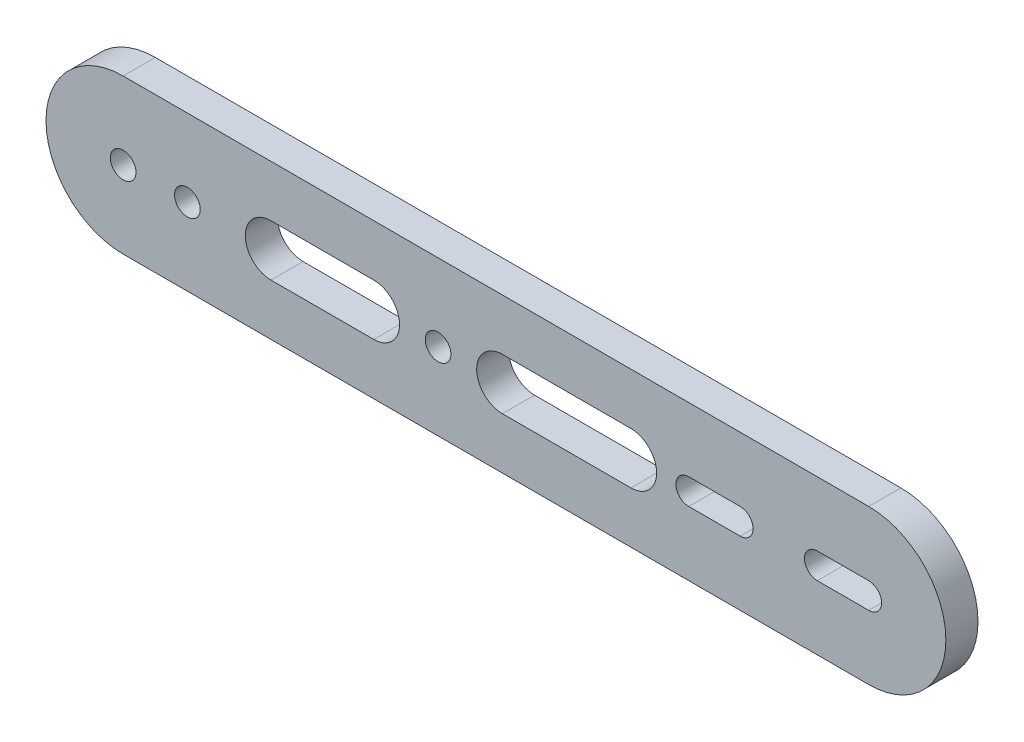
from build123d import *

# Parameters (mm, degrees)
SKETCH_1_R      = 2
EXTRUDE_1_DEPTH = 5


with BuildPart() as part:
    # 草图1 → 凸台-拉伸1 (new body)
    with BuildSketch(Plane.XY):
        with BuildLine():
            Line((0, 12), (116, 12))
            ThreePointArc((116, 12), (128, 0), (116, -12))
            Line((116, -12), (0, -12))
            ThreePointArc((0, -12), (-12, 0), (0, 12))
        make_face()
        with Locations((49, 0)):
            Circle(SKETCH_1_R, mode=Mode.SUBTRACT)
        Circle(SKETCH_1_R, mode=Mode.SUBTRACT)
        with Locations((10, 0)):
            Circle(SKETCH_1_R, mode=Mode.SUBTRACT)
        with BuildLine():
            Line((23, 4), (39, 4))
            ThreePointArc((39, 4), (43, 0), (39, -4))
            Line((39, -4), (23, -4))
            ThreePointArc((23, -4), (19, 0), (23, 4))
        make_face(mode=Mode.SUBTRACT)
        with BuildLine():
            Line((59, 4), (79, 4))
            ThreePointArc((79, 4), (83, 0), (79, -4))
            Line((79, -4), (59, -4))
            ThreePointArc((59, -4), (55, 0), (59, 4))
        make_face(mode=Mode.SUBTRACT)
        with BuildLine():
            Line((108, 2), (116, 2))
            ThreePointArc((116, 2), (118, 0), (116, -2))
            Line((116, -2), (108, -2))
            ThreePointArc((108, -2), (106, 0), (108, 2))
        make_face(mode=Mode.SUBTRACT)
        with BuildLine():
            Line((88, 2), (96, 2))
            ThreePointArc((96, 2), (98, 0), (96, -2))
            Line((96, -2), (88, -2))
            ThreePointArc((88, -2), (86, 0), (88, 2))
        make_face(mode=Mode.SUBTRACT)
    extrude(amount=EXTRUDE_1_DEPTH)


solid = part.part
